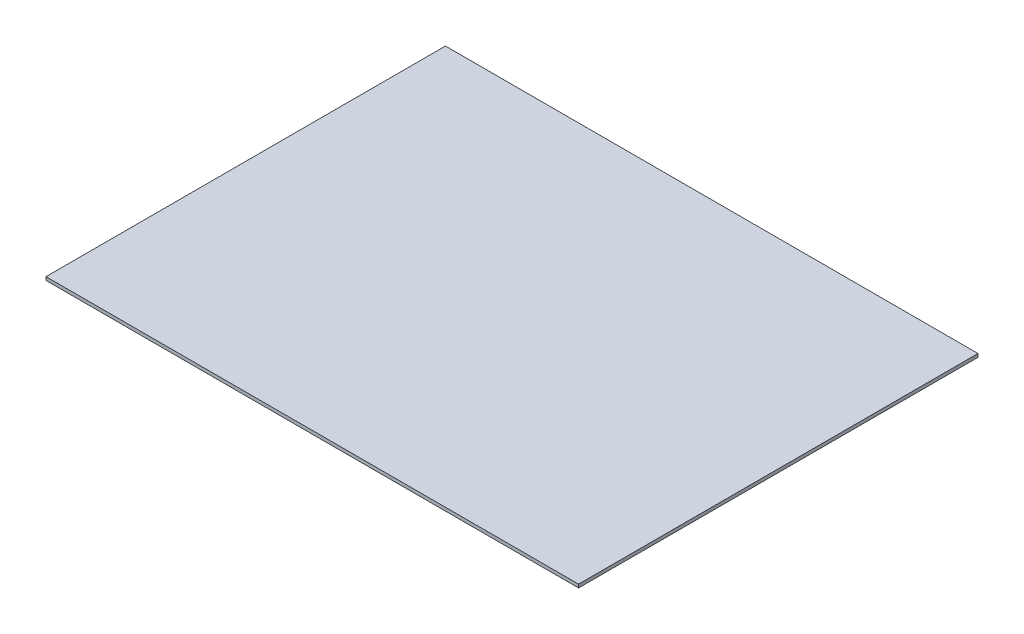
from build123d import *

# Parameters (mm, degrees)
SKETCH1_W           = 800
SKETCH1_H           = 600
BOSS_EXTRUDE1_DEPTH = 5


with BuildPart() as part:
    # Sketch1 → Boss-Extrude1 (new body)
    with BuildSketch(Plane(origin=(0, 0, 0), x_dir=(1, 0, 0), z_dir=(0, 1, 0))):
        Rectangle(SKETCH1_W, SKETCH1_H)
    extrude(amount=BOSS_EXTRUDE1_DEPTH)


solid = part.part
